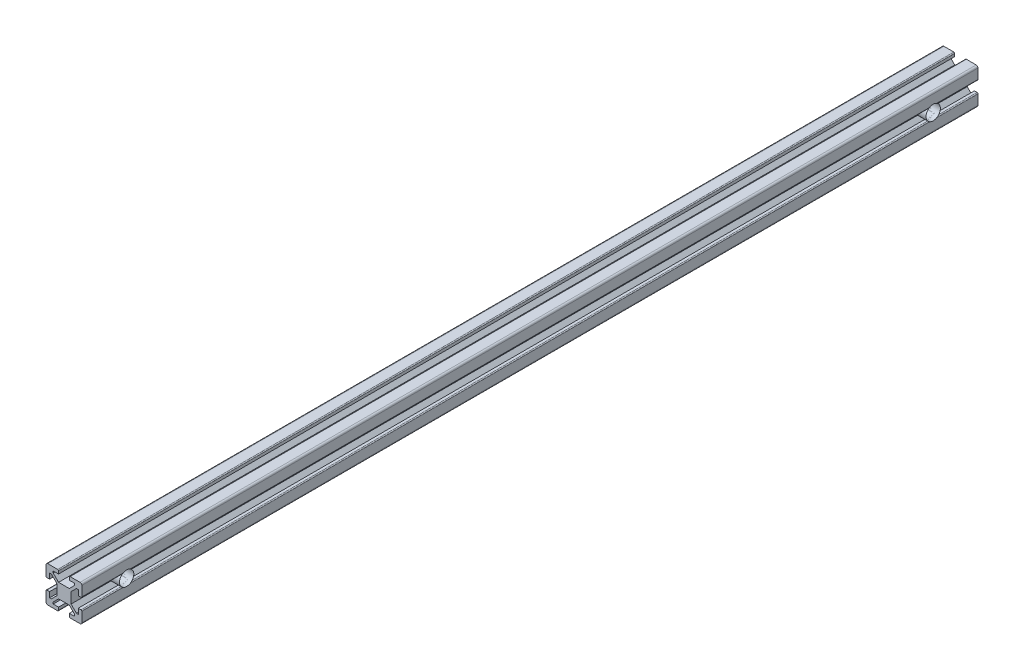
from build123d import *

# Parameters (mm, degrees)
ESTRUSIONE_ESTRUSIONE1_DEPTH = 500
SCHIZZO2_R                   = 4.005
ESTRUSIONE_ESTRUSIONE4_DEPTH = 20
SCHIZZO6_R                   = 4
TAGLIO_ESTRUSIONE20_DEPTH    = 20


with BuildPart() as part:
    # Schizzo1 → Estrusione-Estrusione1 (new body)
    with BuildSketch(Plane.XY):
        with BuildLine():
            Line((-4, -3), (-4, 3))
            Line((-4, 3), (-7, 6))
            Line((-7, 6), (-8, 6))
            Line((-8, 6), (-8, 3))
            Line((-8, 3), (-9.5, 3))
            ThreePointArc((-9.5, 3), (-9.853553391, 3.146446609), (-10, 3.5))
            Line((-10, 3.5), (-10, 9))
            ThreePointArc((-10, 9), (-9.707106781, 9.707106781), (-9, 10))
            Line((-9, 10), (-3.5, 10))
            ThreePointArc((-3.5, 10), (-3.146446609, 9.853553391), (-3, 9.5))
            Line((-3, 9.5), (-3, 8))
            Line((-3, 8), (-6, 8))
            Line((-6, 8), (-6, 7))
            Line((-6, 7), (-3, 4))
            Line((-3, 4), (3, 4))
            Line((3, 4), (6, 7))
            Line((6, 7), (6, 8))
            Line((6, 8), (3, 8))
            Line((3, 8), (3, 9.5))
            ThreePointArc((3, 9.5), (3.146446609, 9.853553391), (3.5, 10))
            Line((3.5, 10), (9, 10))
            ThreePointArc((9, 10), (9.707106781, 9.707106781), (10, 9))
            Line((10, 9), (10, 3.5))
            ThreePointArc((10, 3.5), (9.853553391, 3.146446609), (9.5, 3))
            Line((9.5, 3), (8, 3))
            Line((8, 3), (8, 6))
            Line((8, 6), (7, 6))
            Line((7, 6), (4, 3))
            Line((4, 3), (4, -3))
            Line((4, -3), (7, -6))
            Line((7, -6), (8, -6))
            Line((8, -6), (8, -3))
            Line((8, -3), (9.5, -3))
            ThreePointArc((9.5, -3), (9.853553391, -3.146446609), (10, -3.5))
            Line((10, -3.5), (10, -9))
            ThreePointArc((10, -9), (9.707106781, -9.707106781), (9, -10))
            Line((9, -10), (3.5, -10))
            ThreePointArc((3.5, -10), (3.146446609, -9.853553391), (3, -9.5))
            Line((3, -9.5), (3, -8))
            Line((3, -8), (6, -8))
            Line((6, -8), (6, -7))
            Line((6, -7), (3, -4))
            Line((3, -4), (-3, -4))
            Line((-3, -4), (-6, -7))
            Line((-6, -7), (-6, -8))
            Line((-6, -8), (-3, -8))
            Line((-3, -8), (-3, -9.5))
            ThreePointArc((-3, -9.5), (-3.146446609, -9.853553391), (-3.5, -10))
            Line((-3.5, -10), (-9, -10))
            ThreePointArc((-9, -10), (-9.707106781, -9.707106781), (-10, -9))
            Line((-10, -9), (-10, -3.5))
            ThreePointArc((-10, -3.5), (-9.853553391, -3.146446609), (-9.5, -3))
            Line((-9.5, -3), (-8, -3))
            Line((-8, -3), (-8, -6))
            Line((-8, -6), (-7, -6))
            Line((-7, -6), (-4, -3))
        make_face()
    extrude(amount=ESTRUSIONE_ESTRUSIONE1_DEPTH)

    # Schizzo2 → Estrusione-Estrusione4 (add)
    with BuildSketch(Plane.ZY.offset(10)):
        with Locations((25, 0)):
            Circle(SCHIZZO2_R)
        with Locations((475, 0)):
            Circle(SCHIZZO2_R)
    extrude(amount=-ESTRUSIONE_ESTRUSIONE4_DEPTH)

    # Schizzo6 → Taglio-Estrusione20 (cut)
    with BuildSketch(Plane.ZY.offset(10)):
        with Locations((25, 0)):
            Circle(SCHIZZO6_R)
        with Locations((475, 0)):
            Circle(SCHIZZO6_R)
    extrude(amount=-TAGLIO_ESTRUSIONE20_DEPTH, mode=Mode.SUBTRACT)


solid = part.part
